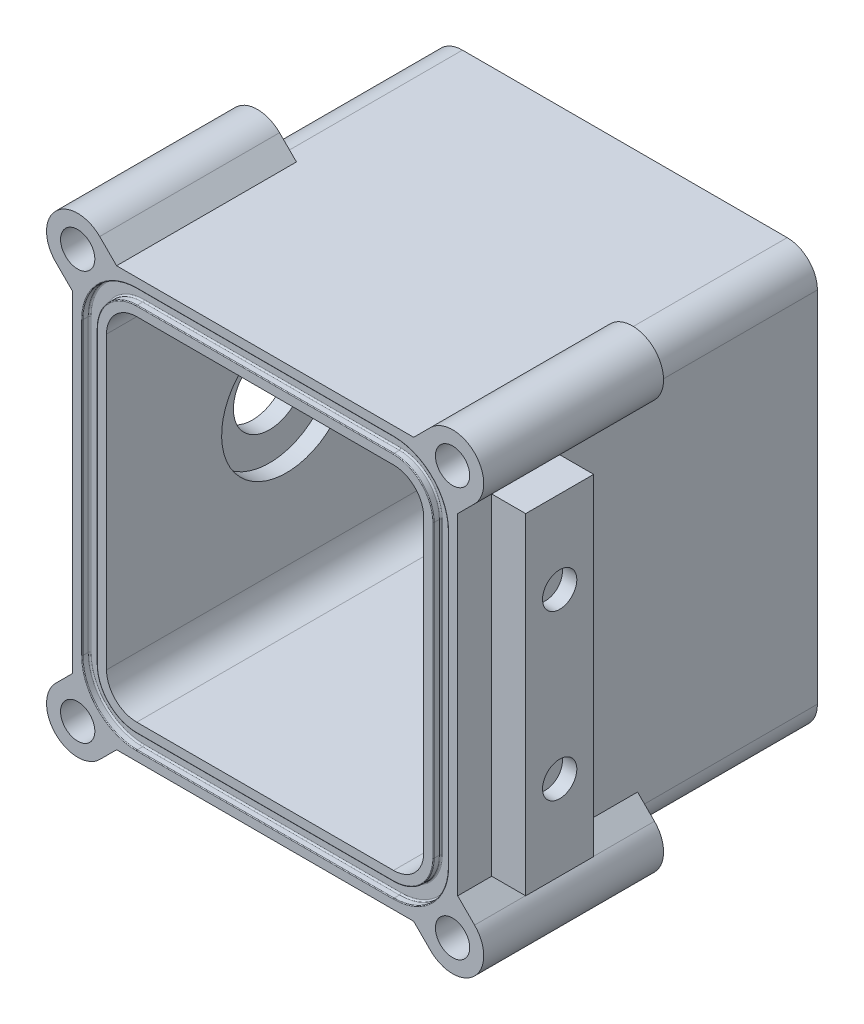
from build123d import *

# Parameters (mm, degrees)
BOSS_EXTRUDE1_DEPTH     = 31.75
SHELL1_T                = -6
FILLET1_R               = 5.334
CUT_EXTRUDE1_DEPTH      = 1.2954
FILLET2_R               = 0.254
FILLET3_R               = 0.127
BOSS_EXTRUDE2_DEPTH     = 31.75
SKETCH4_R               = 3.025
CUT_EXTRUDE2_DEPTH      = 9
MIRROR2_COPY_1_DEPTH    = 31.75
MIRROR2_COPY_2_SKETCH_R = 3.025
MIRROR2_COPY_2_DEPTH    = 9
SKETCH8_W               = 12
SKETCH8_H               = 58.443650814
BOSS_EXTRUDE3_DEPTH     = 6
SKETCH12_R              = 3.025
CUT_EXTRUDE6_DEPTH      = 2.54
SKETCH13_R              = 6.35
CUT_EXTRUDE10_DEPTH     = 6
SKETCH16_R              = 11.43
CUT_EXTRUDE14_DEPTH     = 3


with BuildPart() as part:
    # Sketch1 → Boss-Extrude1 (new, symmetric)
    with BuildSketch(Plane.XY):
        Polygon((-34, -37), (-34, -16.68), (-34, 16.68), (-34, 37), (34, 37), (34, -37), align=None)
    extrude(amount=BOSS_EXTRUDE1_DEPTH, both=True)

    # Shell1
    shell1_openings = [part.faces().sort_by_distance(p)[0] for p in [
        (0, 0, 31.75),
    ]]
    offset(amount=SHELL1_T, openings=shell1_openings, kind=Kind.INTERSECTION)

    # Fillet1
    fillet1_edges = [part.edges().sort_by_distance(p)[0] for p in [
        (-34, -37, 0),
        (-34, 37, 0),
        (34, 37, 0),
        (34, -37, 0),
        (-28, -31, 3),
        (28, -31, 3),
        (28, 31, 3),
        (-28, 31, 3),
    ]]
    fillet(fillet1_edges, radius=FILLET1_R)

    # Sketch2 → Cut-Extrude1 (cut)
    with BuildSketch(Plane.XY.offset(31.75)):
        with BuildLine():
            Line((32.2827, -25.666), (32.2827, 25.666))
            ThreePointArc((32.2827, 25.666), (29.466033783, 32.466033783), (22.666, 35.2827))
            Line((22.666, 35.2827), (-22.666, 35.2827))
            ThreePointArc((-22.666, 35.2827), (-29.466033783, 32.466033783), (-32.2827, 25.666))
            Line((-32.2827, 25.666), (-32.2827, -25.666))
            ThreePointArc((-32.2827, -25.666), (-29.466033783, -32.466033783), (-22.666, -35.2827))
            Line((-22.666, -35.2827), (22.666, -35.2827))
            ThreePointArc((22.666, -35.2827), (29.466033783, -32.466033783), (32.2827, -25.666))
        make_face()
        with BuildLine():
            Line((-29.7173, 25.666), (-29.7173, -25.666))
            ThreePointArc((-29.7173, -25.666), (-27.652022046, -30.652022046), (-22.666, -32.7173))
            Line((-22.666, -32.7173), (22.666, -32.7173))
            ThreePointArc((22.666, -32.7173), (27.652022046, -30.652022046), (29.7173, -25.666))
            Line((29.7173, -25.666), (29.7173, 25.666))
            ThreePointArc((29.7173, 25.666), (27.652022046, 30.652022046), (22.666, 32.7173))
            Line((22.666, 32.7173), (-22.666, 32.7173))
            ThreePointArc((-22.666, 32.7173), (-27.652022046, 30.652022046), (-29.7173, 25.666))
        make_face(mode=Mode.SUBTRACT)
    extrude(amount=-CUT_EXTRUDE1_DEPTH, mode=Mode.SUBTRACT)

    # Fillet2
    fillet2_edges = [part.edges().sort_by_distance(p)[0] for p in [
        (29.466033783, -32.466033783, 30.4546),
        (0, -35.2827, 30.4546),
        (-29.466033783, -32.466033783, 30.4546),
        (-32.2827, 0, 30.4546),
        (-29.466033783, 32.466033783, 30.4546),
        (0, 35.2827, 30.4546),
        (29.466033783, 32.466033783, 30.4546),
        (32.2827, 0, 30.4546),
        (0, 32.7173, 30.4546),
        (-27.652022046, 30.652022046, 30.4546),
        (-29.7173, 0, 30.4546),
        (-27.652022046, -30.652022046, 30.4546),
        (0, -32.7173, 30.4546),
        (27.652022046, -30.652022046, 30.4546),
        (29.7173, 0, 30.4546),
        (27.652022046, 30.652022046, 30.4546),
    ]]
    fillet(fillet2_edges, radius=FILLET2_R)

    # Fillet3
    fillet3_edges = [part.edges().sort_by_distance(p)[0] for p in [
        (29.466033783, -32.466033783, 31.75),
        (32.2827, 0, 31.75),
        (29.466033783, 32.466033783, 31.75),
        (0, 35.2827, 31.75),
        (-29.466033783, 32.466033783, 31.75),
        (-32.2827, 0, 31.75),
        (-29.466033783, -32.466033783, 31.75),
        (0, -35.2827, 31.75),
        (-27.652022046, 30.652022046, 31.75),
        (0, 32.7173, 31.75),
        (27.652022046, 30.652022046, 31.75),
        (29.7173, 0, 31.75),
        (27.652022046, -30.652022046, 31.75),
        (0, -32.7173, 31.75),
        (-27.652022046, -30.652022046, 31.75),
        (-29.7173, 0, 31.75),
    ]]
    fillet(fillet3_edges, radius=FILLET3_R)

    # Sketch3 → Boss-Extrude2 (add)
    with BuildSketch(Plane.XY.offset(31.75)):
        with BuildLine():
            Line((34, -29.221825407), (34, -31.666))
            ThreePointArc((34, -31.666), (32.437707571, -35.437707571), (28.666, -37))
            Line((28.666, -37), (26.221825407, -37))
            Line((26.221825407, -37), (29.202282953, -39.980457546))
            ThreePointArc((29.202282953, -39.980457546), (36.980457546, -39.980457546), (36.980457546, -32.202282953))
            Line((36.980457546, -32.202282953), (34, -29.221825407))
        make_face()
    boss_extrude2 = extrude(amount=-BOSS_EXTRUDE2_DEPTH)

    # Sketch4 → Cut-Extrude2 (cut)
    with BuildSketch(Plane.XY.offset(31.75)):
        with Locations((33.09137025, -36.09137025)):
            Circle(SKETCH4_R)
    cut_extrude2 = extrude(amount=-CUT_EXTRUDE2_DEPTH, mode=Mode.SUBTRACT)

    # Mirror1: Boss-Extrude2, Cut-Extrude2 across plane
    add(boss_extrude2.mirror(Plane.ZX))
    add(cut_extrude2.mirror(Plane.ZX), mode=Mode.SUBTRACT)

    # Mirror2: Boss-Extrude2, Cut-Extrude2 across plane
    add(boss_extrude2.mirror(Plane(origin=(0, 0, 0), x_dir=(0, 0, 1), z_dir=(1, 0, 0))))
    add(cut_extrude2.mirror(Plane(origin=(0, 0, 0), x_dir=(0, 0, 1), z_dir=(1, 0, 0))), mode=Mode.SUBTRACT)

    # Mirror2 copy 1 sketch → Mirror2 copy 1 (add)
    with BuildSketch(Plane(origin=(0, 0, 31.75), x_dir=(-1, 0, 0), z_dir=(0, 0, 1))):
        with BuildLine():
            Line((34, -29.221825407), (34, -31.666))
            ThreePointArc((34, -31.666), (32.437707571, -35.437707571), (28.666, -37))
            Line((28.666, -37), (26.221825407, -37))
            Line((26.221825407, -37), (29.202282953, -39.980457546))
            ThreePointArc((29.202282953, -39.980457546), (36.980457546, -39.980457546), (36.980457546, -32.202282953))
            Line((36.980457546, -32.202282953), (34, -29.221825407))
        make_face()
    extrude(amount=-MIRROR2_COPY_1_DEPTH)

    # Mirror2 copy 2 sketch → Mirror2 copy 2 (cut)
    with BuildSketch(Plane(origin=(0, 0, 31.75), x_dir=(-1, 0, 0), z_dir=(0, 0, 1))):
        with Locations((33.09137025, -36.09137025)):
            Circle(MIRROR2_COPY_2_SKETCH_R)
    extrude(amount=-MIRROR2_COPY_2_DEPTH, mode=Mode.SUBTRACT)

    # Sketch8 → Boss-Extrude3 (add)
    with BuildSketch(Plane.ZY.offset(34)):
        with Locations((19.75, 0)):
            Rectangle(SKETCH8_W, SKETCH8_H)
    boss_extrude3 = extrude(amount=BOSS_EXTRUDE3_DEPTH)

    # Sketch12 → Cut-Extrude6 (cut)
    with BuildSketch(Plane.ZY.offset(40)):
        with Locations(Location((19.75, 14.616825407, 0), (0, 0, 270))):
            Circle(SKETCH12_R)
        with Locations(Location((19.75, -14.339174593, 0), (0, 0, 270))):
            Circle(SKETCH12_R)
    cut_extrude6 = extrude(amount=-CUT_EXTRUDE6_DEPTH, mode=Mode.SUBTRACT)

    # Sketch13 → Cut-Extrude10 (cut)
    with BuildSketch(Plane.ZY.offset(34)):
        with Locations(Location((0, 0, 0), (0, 0, 270))):
            Circle(SKETCH13_R)
    extrude(amount=-CUT_EXTRUDE10_DEPTH, mode=Mode.SUBTRACT)

    # Sketch16 → Cut-Extrude14 (cut)
    with BuildSketch(Plane(origin=(-28, 0, 0), x_dir=(0, 0, -1), z_dir=(1, 0, 0))):
        with Locations(Location((0, 0, 0), (0, 0, 90))):
            Circle(SKETCH16_R)
    extrude(amount=-CUT_EXTRUDE14_DEPTH, mode=Mode.SUBTRACT)

    # Mirror5: Boss-Extrude3 across plane
    add(boss_extrude3.mirror(Plane(origin=(0, 0, 0), x_dir=(0, 0, 1), z_dir=(1, 0, 0))))

    # Mirror6: Cut-Extrude6 across plane
    add(cut_extrude6.mirror(Plane(origin=(0, 0, 0), x_dir=(0, 0, 1), z_dir=(1, 0, 0))), mode=Mode.SUBTRACT)


solid = part.part
